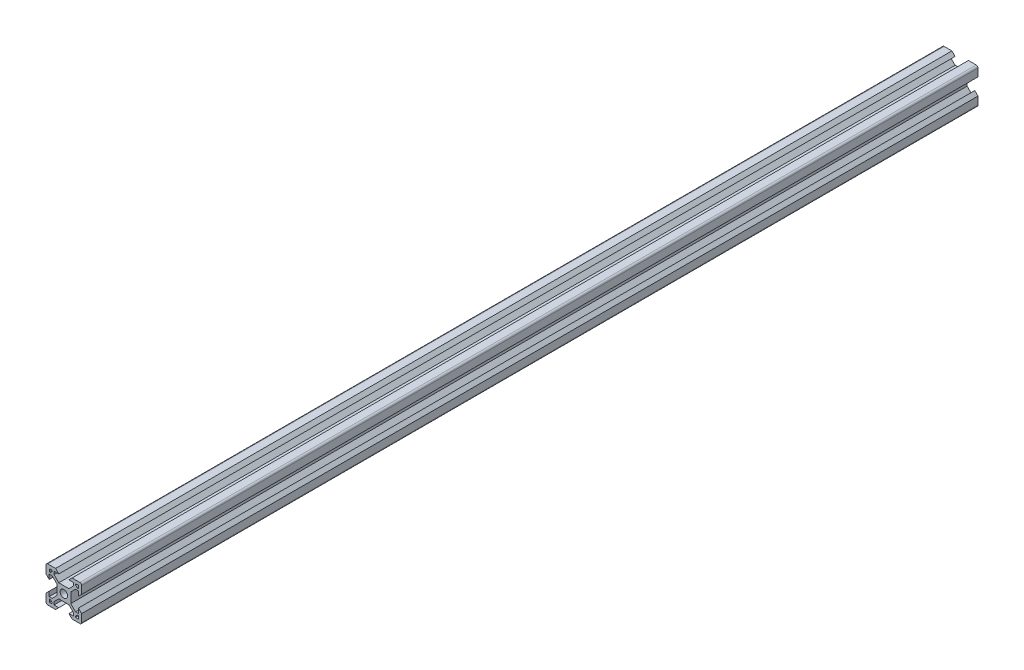
from build123d import *

# Parameters (mm, degrees)
SKETCH1_R           = 2.1
BOSS_EXTRUDE1_DEPTH = 503


with BuildPart() as part:
    # Sketch1 → Boss-Extrude1 (new body)
    with BuildSketch(Plane.XY):
        with BuildLine():
            Line((0, 1), (0, 5.36))
            Line((0, 5.36), (1.8, 7.16))
            Line((1.8, 7.16), (1.8, 4.500660172))
            Line((1.8, 4.500660172), (3.44, 4.500660172))
            Line((3.44, 4.500660172), (6.099339828, 7.16))
            Line((6.099339828, 7.16), (6.099339828, 12.84))
            Line((6.099339828, 12.84), (3.44, 15.499339828))
            Line((3.44, 15.499339828), (1.8, 15.499339828))
            Line((1.8, 15.499339828), (1.8, 12.84))
            Line((1.8, 12.84), (0, 14.64))
            Line((0, 14.64), (0, 19))
            ThreePointArc((0, 19), (0.292893219, 19.707106781), (1, 20))
            Line((1, 20), (5.36, 20))
            Line((5.36, 20), (7.16, 18.2))
            Line((7.16, 18.2), (4.500660172, 18.2))
            Line((4.500660172, 18.2), (4.500660172, 16.56))
            Line((4.500660172, 16.56), (7.16, 13.900660172))
            Line((7.16, 13.900660172), (12.84, 13.900660172))
            Line((12.84, 13.900660172), (15.464579042, 16.525239214))
            Line((15.464579042, 16.525239214), (15.464579042, 18.165239214))
            Line((15.464579042, 18.165239214), (12.84, 18.2))
            Line((12.84, 18.2), (14.64, 20))
            Line((14.64, 20), (19, 20))
            ThreePointArc((19, 20), (19.707106781, 19.707106781), (20, 19))
            Line((20, 19), (20, 14.674581351))
            Line((20, 14.674581351), (18.155899385, 12.84))
            Line((18.155899385, 12.84), (18.155899385, 15.455239214))
            Line((18.155899385, 15.455239214), (16.515899385, 15.455239214))
            Line((16.515899385, 15.455239214), (13.900660172, 12.84))
            Line((13.900660172, 12.84), (13.900660172, 7.16))
            Line((13.900660172, 7.16), (16.56, 4.500660172))
            Line((16.56, 4.500660172), (18.2, 4.500660172))
            Line((18.2, 4.500660172), (18.2, 7.16))
            Line((18.2, 7.16), (20, 5.36))
            Line((20, 5.36), (20, 1))
            ThreePointArc((20, 1), (19.707106781, 0.292893219), (19, 0))
            Line((19, 0), (14.64, 0))
            Line((14.64, 0), (12.84, 1.8))
            Line((12.84, 1.8), (15.499339828, 1.8))
            Line((15.499339828, 1.8), (15.499339828, 3.44))
            Line((15.499339828, 3.44), (12.84, 6.099339828))
            Line((12.84, 6.099339828), (7.16, 6.099339828))
            Line((7.16, 6.099339828), (4.500660172, 3.44))
            Line((4.500660172, 3.44), (4.500660172, 1.8))
            Line((4.500660172, 1.8), (7.16, 1.8))
            Line((7.16, 1.8), (5.36, 0))
            Line((5.36, 0), (1, 0))
            ThreePointArc((1, 0), (0.292893219, 0.292893219), (0, 1))
        make_face()
        with Locations((10.02040103, 9.97959897)):
            Circle(SKETCH1_R, mode=Mode.SUBTRACT)
        Polygon((16.534579042, 18.2), (16.534579042, 17.576559557), (17.585899385, 16.525239214), (18.2, 16.525239214), (18.2, 18.2), align=None, mode=Mode.SUBTRACT)
        Polygon((18.2, 1.75919794), (18.2, 3.433958726), (17.585899385, 3.433958726), (16.534579042, 2.382638382), (16.534579042, 1.75919794), align=None, mode=Mode.SUBTRACT)
        Polygon((2.454902675, 16.525239214), (1.84080206, 16.525239214), (1.84080206, 18.2), (3.506223018, 18.2), (3.506223018, 17.576559557), align=None, mode=Mode.SUBTRACT)
        Polygon((3.506223018, 1.75919794), (1.84080206, 1.75919794), (1.84080206, 3.433958726), (2.454902675, 3.433958726), (3.506223018, 2.382638382), align=None, mode=Mode.SUBTRACT)
    extrude(amount=-BOSS_EXTRUDE1_DEPTH)


solid = part.part
